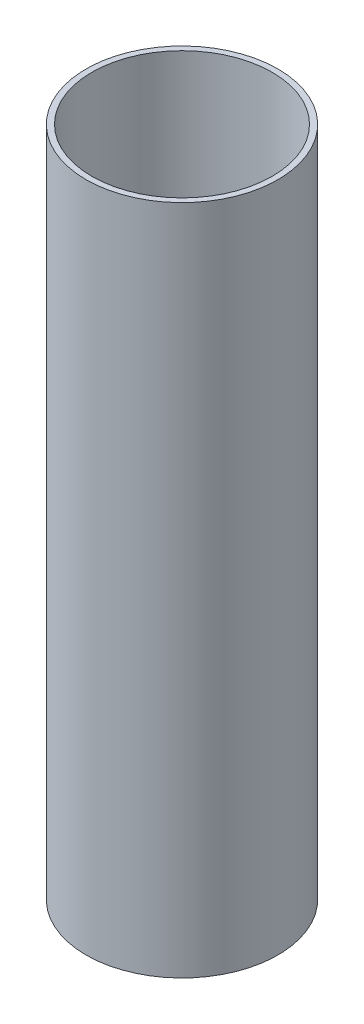
from build123d import *

# Parameters (mm, degrees)
SKETCH1_R           = 6.35
SKETCH1_R_2         = 5.969
BOSS_EXTRUDE1_DEPTH = 44.45


with BuildPart() as part:
    # Sketch1 → Boss-Extrude1 (new body)
    with BuildSketch(Plane(origin=(0, 0, 0), x_dir=(1, 0, 0), z_dir=(0, 1, 0))):
        Circle(SKETCH1_R)
        Circle(SKETCH1_R_2, mode=Mode.SUBTRACT)
    extrude(amount=BOSS_EXTRUDE1_DEPTH)


solid = part.part
